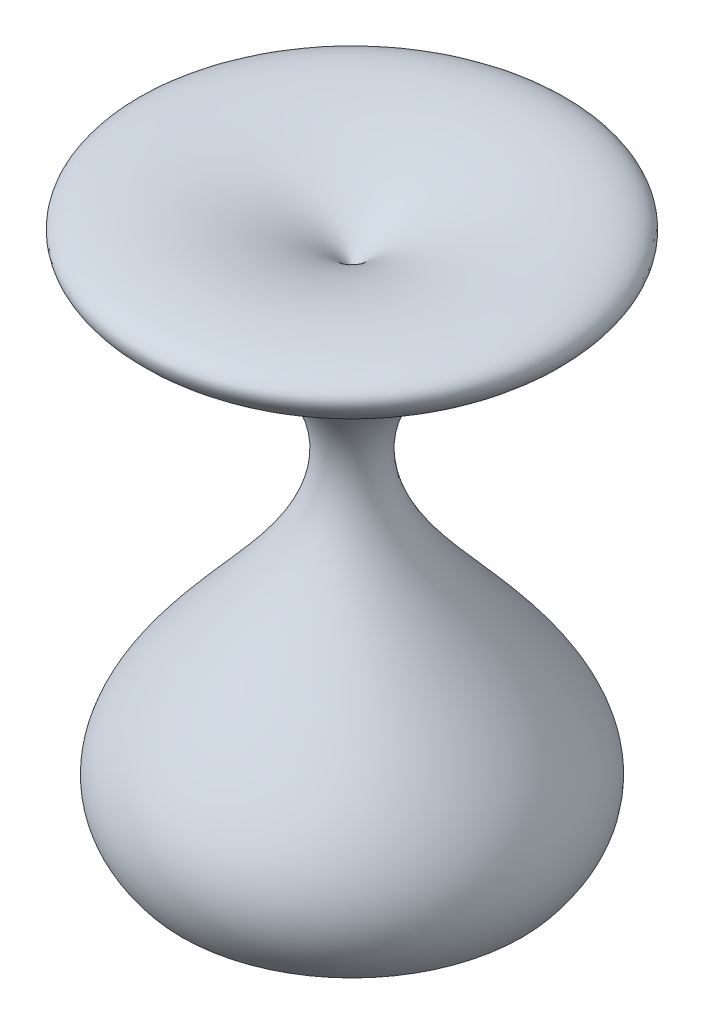
from build123d import *

# Parameters (mm, degrees)
SKETCH3_R          = 16.596750679
CUT_EXTRUDE1_DEPTH = 5


with BuildPart() as part:
    # Sketch2 → Revolve1 (revolve)
    with BuildSketch(Plane.XY):
        with BuildLine():
            Line((21.150277459, -32.103561808), (33.007781624, -32.103561808))
            Line((33.007781624, -32.103561808), (33.007781624, 19.867626659))
            add(Edge.make_bspline(
                [(21.150277459, 17.218609771), (-3.215919918, 27.289863671), (27.784227383, 28.027296079), (33.007781624, 19.867626659)],
                knots=[0, 0, 0, 0, 1, 1, 1, 1], degree=3))
            add(Edge.make_bspline(
                [(21.150277459, 17.218609771), (50.58194838, -2.255931795), (-4.106177089, -15.686617481), (21.150277459, -32.103561808)],
                knots=[0, 0, 0, 0, 1, 1, 1, 1], degree=3))
        make_face()
    revolve(axis=Axis((33.007781624, 30.715981534, 0), (0, -1, 0)))

    # Sketch3 → Cut-Extrude1 (cut)
    with BuildSketch(Plane(origin=(0, -32.103561808, 0), x_dir=(-1, 0, 0), z_dir=(0, -1, 0))):
        with Locations((-33.007781624, 0)):
            Circle(SKETCH3_R)
    extrude(amount=-CUT_EXTRUDE1_DEPTH, mode=Mode.SUBTRACT)


solid = part.part
